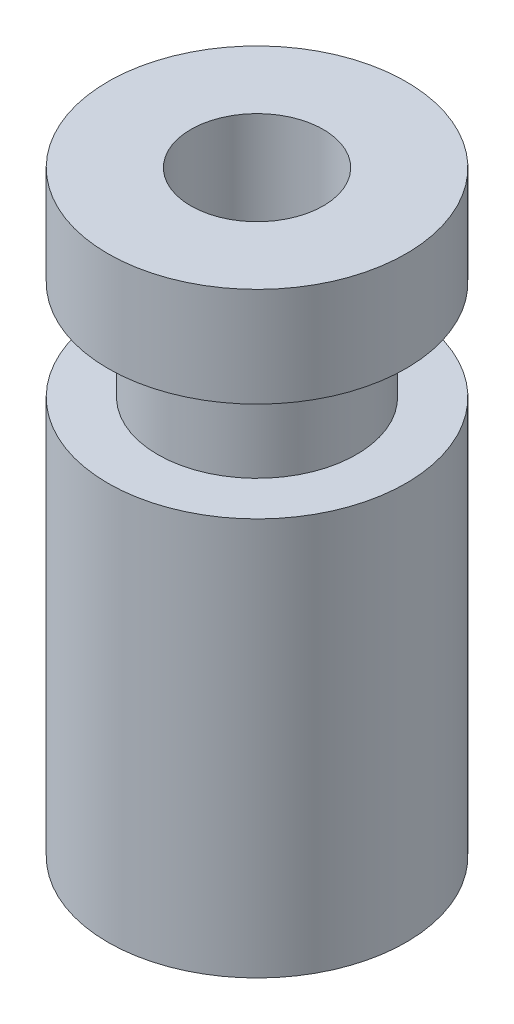
from build123d import *

# Parameters (mm, degrees)
SKETCH1_R           = 2.25
SKETCH1_R_2         = 1
BOSS_EXTRUDE1_DEPTH = 6
SKETCH2_R           = 1.5
SKETCH2_R_2         = 1
BOSS_EXTRUDE2_DEPTH = 1.5
SKETCH3_R           = 2.25
SKETCH3_R_2         = 1
BOSS_EXTRUDE3_DEPTH = 1.5


with BuildPart() as part:
    # Sketch1 → Boss-Extrude1 (new body)
    with BuildSketch(Plane(origin=(0, 0, 0), x_dir=(1, 0, 0), z_dir=(0, 1, 0))):
        Circle(SKETCH1_R)
        Circle(SKETCH1_R_2, mode=Mode.SUBTRACT)
    extrude(amount=BOSS_EXTRUDE1_DEPTH)

    # Sketch2 → Boss-Extrude2 (add)
    with BuildSketch(Plane(origin=(0, 6, 0), x_dir=(1, 0, 0), z_dir=(0, 1, 0))):
        Circle(SKETCH2_R)
        Circle(SKETCH2_R_2, mode=Mode.SUBTRACT)
    extrude(amount=BOSS_EXTRUDE2_DEPTH)

    # Sketch3 → Boss-Extrude3 (add)
    with BuildSketch(Plane(origin=(0, 7.5, 0), x_dir=(1, 0, 0), z_dir=(0, 1, 0))):
        Circle(SKETCH3_R)
        Circle(SKETCH3_R_2, mode=Mode.SUBTRACT)
    extrude(amount=BOSS_EXTRUDE3_DEPTH)


solid = part.part
